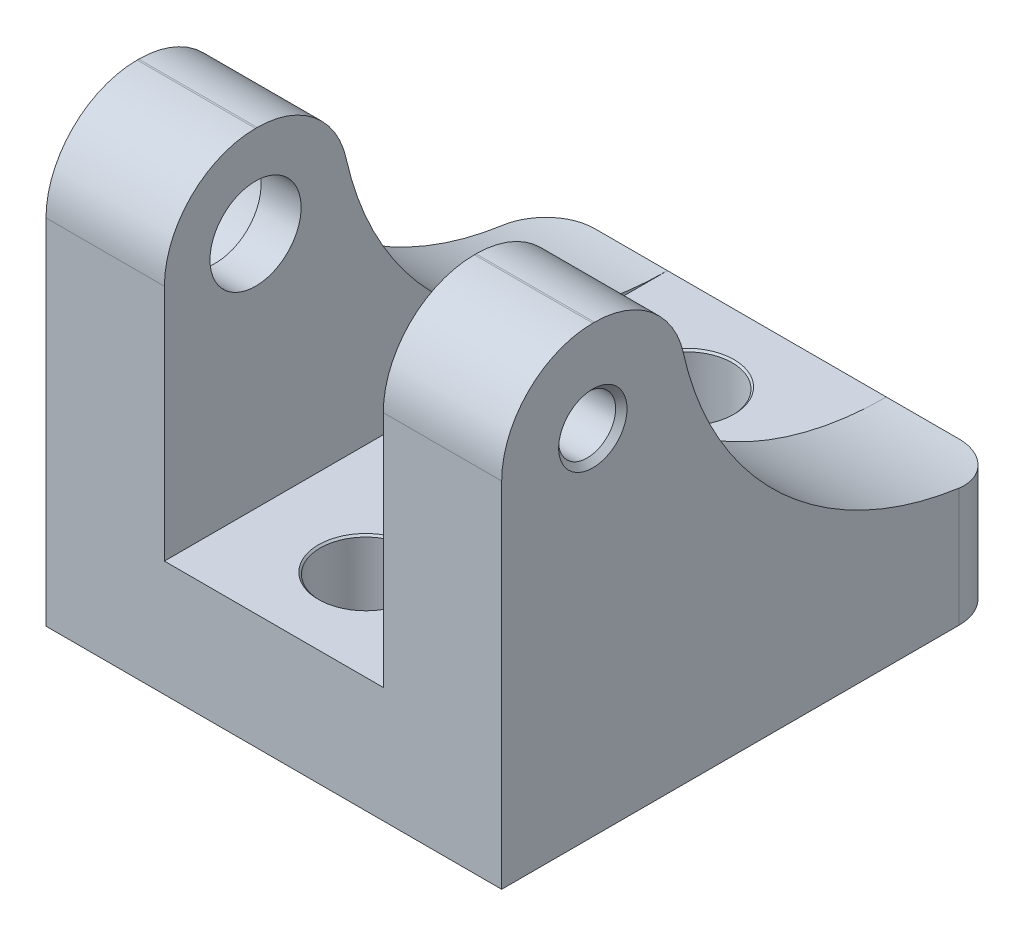
from build123d import *

# Parameters (mm, degrees)
SKETCH1_W                         = 63.5
SKETCH1_H                         = 70.104
BOSS_EXTRUDE1_DEPTH               = 61.976
SKETCH2_R                         = 45.865892013
CUT_EXTRUDE1_DEPTH                = 63.5
FILLET2_R                         = 12.7
SKETCH3_W                         = 28.956
SKETCH3_H                         = 47.389892013
CUT_EXTRUDE2_DEPTH                = 71.104
SKETCH4_R                         = 6.35
CUT_EXTRUDE3_DEPTH                = 17.110107987
CHAMFER1_SIZE                     = 0.254
FILLET4_R                         = 6.35
SKETCH5_R                         = 10.414
CUT_EXTRUDE4_DEPTH                = 10.922
CUT_EXTRUDE5_REACH                = 54.578
SKETCH6_R                         = 6.35
F_3_8_16_TAPPED_HOLE1_D           = 7.9375
F_3_8_16_TAPPED_HOLE1_DEPTH       = 17.272
F_3_8_16_TAPPED_HOLE1_CSINK_D     = 9.525
F_3_8_16_TAPPED_HOLE1_CSINK_ANGLE = 90
SKETCH9_W                         = 30.5
SKETCH9_H                         = 45.865892013
CUT_EXTRUDE6_DEPTH                = 71.1040001


with BuildPart() as part:
    # Sketch1 → Boss-Extrude1 (new body)
    with BuildSketch(Plane(origin=(0, 0, 0), x_dir=(1, 0, 0), z_dir=(0, 1, 0))):
        with Locations((31.75, 35.052)):
            Rectangle(SKETCH1_W, SKETCH1_H)
    extrude(amount=BOSS_EXTRUDE1_DEPTH)

    # Sketch2 → Cut-Extrude1 (cut)
    with BuildSketch(Plane(origin=(63.5, 0, 0), x_dir=(0, 0, -1), z_dir=(1, 0, 0))):
        with Locations((70.104, 61.976)):
            Circle(SKETCH2_R)
    extrude(amount=-CUT_EXTRUDE1_DEPTH, mode=Mode.SUBTRACT)

    # Fillet2
    fillet2_edges = [part.edges().sort_by_distance(p)[0] for p in [
        (31.75, 61.976, -24.238107987),
        (31.75, 61.976, 0),
    ]]
    fillet(fillet2_edges, radius=FILLET2_R)

    # Sketch3 → Cut-Extrude2 (cut, through all)
    with BuildSketch(Plane(origin=(0, 0, -70.104), x_dir=(-1, 0, 0), z_dir=(0, 0, -1))):
        with Locations((-31.75, 39.805053994)):
            Rectangle(SKETCH3_W, SKETCH3_H)
    extrude(amount=-CUT_EXTRUDE2_DEPTH, mode=Mode.SUBTRACT)

    # Sketch4 → Cut-Extrude3 (cut, through all)
    with BuildSketch(Plane(origin=(0, 16.110107987, 0), x_dir=(1, 0, 0), z_dir=(0, 1, 0))):
        with Locations(Location((31.864756847, 57.404, 0), (0, 0, 270))):  # turned: the seam where the file's is
            Circle(SKETCH4_R)
        with Locations(Location((31.864752163, 12.699481562, 0), (0, 0, 270))):  # turned: the seam where the file's is
            Circle(SKETCH4_R)
    extrude(amount=-CUT_EXTRUDE3_DEPTH, mode=Mode.SUBTRACT)

    # Chamfer1
    chamfer1_edges = [part.edges().sort_by_distance(p)[0] for p in [
        (31.864756847, 16.110107987, -63.754),
        (31.864752163, 16.110107987, -19.049481562),
    ]]
    chamfer(chamfer1_edges, length=CHAMFER1_SIZE)

    # Fillet4
    fillet4_edges = [part.edges().sort_by_distance(p)[0] for p in [
        (0, 8.055053993, -70.104),
        (63.5, 8.055053993, -70.104),
    ]]
    fillet(fillet4_edges, radius=FILLET4_R)

    # Sketch5 → Cut-Extrude4 (cut)
    with BuildSketch(Plane.ZY):
        with Locations((-12.7, 49.276)):
            Circle(SKETCH5_R)
    extrude(amount=-CUT_EXTRUDE4_DEPTH, mode=Mode.SUBTRACT)

    # Sketch6 → Cut-Extrude5 (cut, up to next)
    with BuildSketch(Plane.ZY.offset(-10.922), mode=Mode.PRIVATE) as cut_extrude5_sk1:
        with Locations((-12.7, 49.276)):
            Circle(SKETCH6_R)
    cut_extrude5_tool1 = extrude(cut_extrude5_sk1.sketch, amount=-CUT_EXTRUDE5_REACH, mode=Mode.PRIVATE) & part.part
    add(cut_extrude5_tool1.solids().sort_by_distance((10.922, 49.276, -12.7))[0], mode=Mode.SUBTRACT)

    # 3/8-16 Tapped Hole1
    with Locations(Plane(origin=(63.5, 0, 0), x_dir=(0, 0, -1), z_dir=(1, 0, 0))):
        with Locations((12.7, 49.276)):
            CounterSinkHole(F_3_8_16_TAPPED_HOLE1_D / 2, F_3_8_16_TAPPED_HOLE1_CSINK_D / 2, depth=F_3_8_16_TAPPED_HOLE1_DEPTH, counter_sink_angle=F_3_8_16_TAPPED_HOLE1_CSINK_ANGLE)

    # Sketch9 → Cut-Extrude6 (cut, through all)
    with BuildSketch(Plane.XY):
        with Locations((31.75, 39.043053994)):
            Rectangle(SKETCH9_W, SKETCH9_H)
    extrude(amount=-CUT_EXTRUDE6_DEPTH, mode=Mode.SUBTRACT)


solid = part.part
